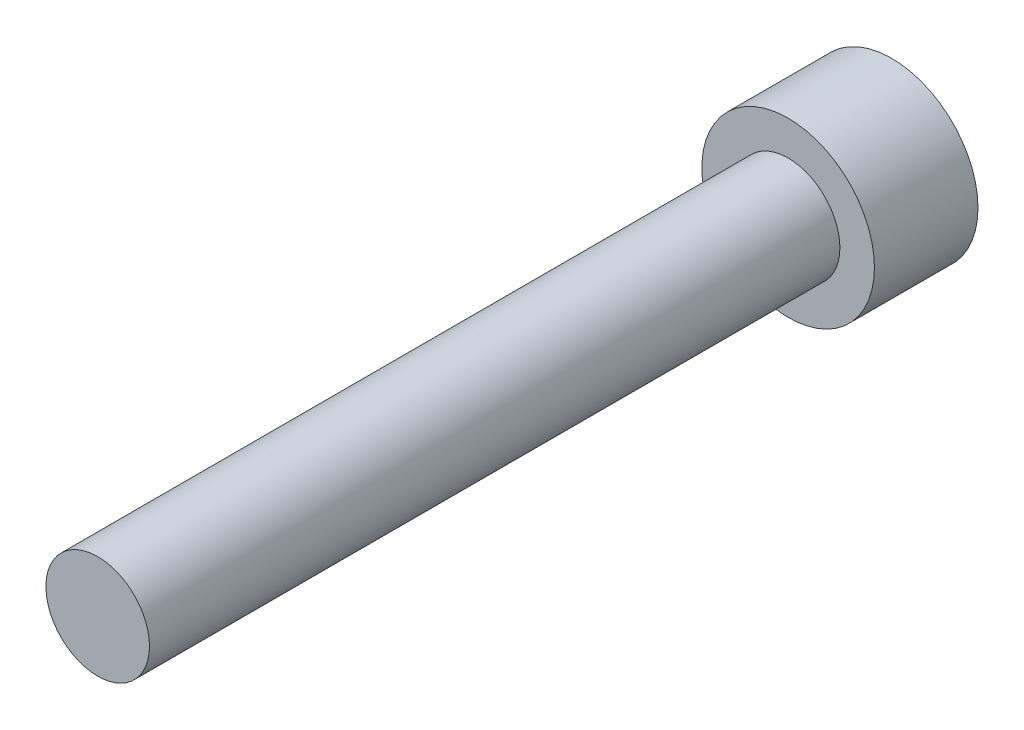
from build123d import *

# Parameters (mm, degrees)
SKETCH1_W = 1.5
SKETCH1_H = 20


with BuildPart() as part:
    # Sketch1 → Revolve1 (revolve)
    with BuildSketch(Plane(origin=(0, 0, 0), x_dir=(1, 0, 0), z_dir=(0, 1, 0))):
        with Locations((0.75, 10)):
            Rectangle(SKETCH1_W, SKETCH1_H)
        Polygon((0, 23), (0, 20), (1.5, 20), (2.5, 20), (2.5, 23), align=None)
    revolve(axis=Axis((0, 0, 0), (0, 0, -1)))


solid = part.part
